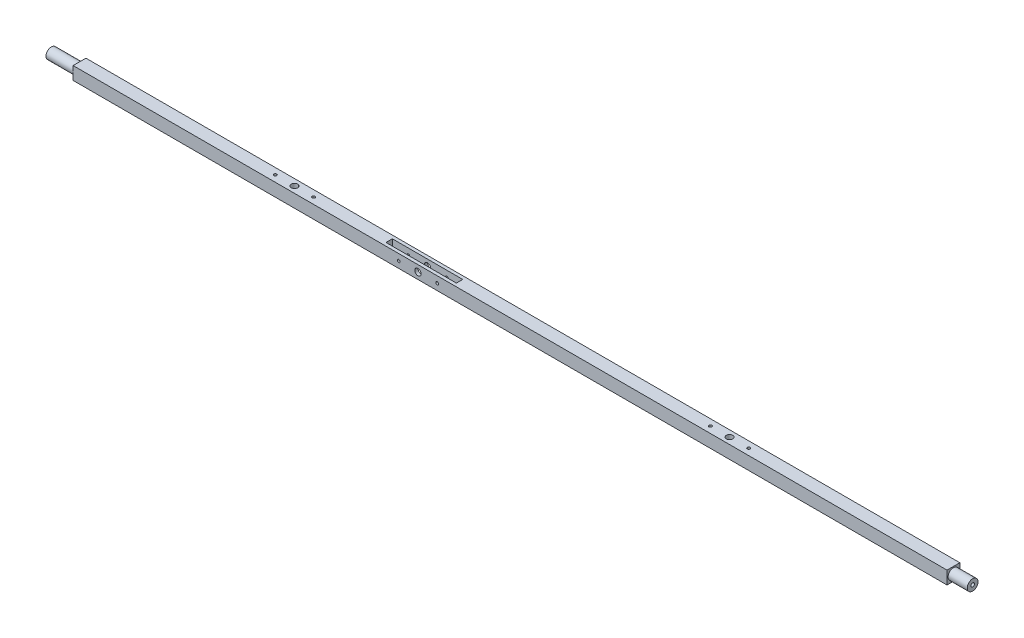
from build123d import *

# Parameters (mm, degrees)
SKETCH1_W                       = 12.7
SKETCH1_H                       = 12.82133758
LENGTH_DEPTH                    = 457.2
SKETCH2_W                       = 12.7
SKETCH2_H                       = 12.82133758
SKETCH2_R                       = 5.334
ROUND_CUT_1_DEPTH               = 19.05
SKETCH3_W                       = 12.7
SKETCH3_H                       = 12.82133758
SKETCH3_R                       = 5.334
ROUND_CUT_2_DEPTH               = 27.94
SKETCH14_R                      = 1.7526
CUT_EXTRUDE6_DEPTH              = 12.7
SKETCH15_R                      = 1.7526
CUT_EXTRUDE7_DEPTH              = 19.05
BOTTOM_WASHER_R                 = 1.4224
BOTTOM_WASHER_BOLTS_DEPTH       = 10.922
BOTTOM_WASHER_CENTER_BOLT_REACH = 14.821
SKETCH18_R                      = 3.175
TOP_WASHER_CENTER_BOLT_REACH    = 14.821
SKETCH17_R                      = 3.175
SKETCH16_R                      = 1.4224
TOP_WASHER_DEPTH                = 10.922
SKETCH19_W                      = 69.85
SKETCH19_H                      = 6.35
CUT_EXTRUDE8_DEPTH              = 13.82133758
SKETCH20_R                      = 1.397
SKETCH20_R_2                    = 3.175
CUT_EXTRUDE9_DEPTH              = 13.7


with BuildPart() as part:
    # Sketch1 → Length (new body, symmetric)
    with BuildSketch(Plane(origin=(0, 0, 0), x_dir=(0, 0, -1), z_dir=(1, 0, 0))):
        Rectangle(SKETCH1_W, SKETCH1_H)
    extrude(amount=LENGTH_DEPTH, both=True)

    # Sketch2 → Round Cut 1 (cut)
    with BuildSketch(Plane(origin=(457.2, 0, 0), x_dir=(0, 0, -1), z_dir=(1, 0, 0))):
        Rectangle(SKETCH2_W, SKETCH2_H)
        Circle(SKETCH2_R, mode=Mode.SUBTRACT)
    extrude(amount=-ROUND_CUT_1_DEPTH, mode=Mode.SUBTRACT)

    # Sketch3 → Round Cut 2 (cut)
    with BuildSketch(Plane.ZY.offset(457.2)):
        Rectangle(SKETCH3_W, SKETCH3_H)
        Circle(SKETCH3_R, mode=Mode.SUBTRACT)
    extrude(amount=-ROUND_CUT_2_DEPTH, mode=Mode.SUBTRACT)

    # Sketch14 → Cut-Extrude6 (cut)
    with BuildSketch(Plane(origin=(457.2, 0, 0), x_dir=(0, 0, -1), z_dir=(1, 0, 0))):
        Circle(SKETCH14_R)
    extrude(amount=-CUT_EXTRUDE6_DEPTH, mode=Mode.SUBTRACT)

    # Sketch15 → Cut-Extrude7 (cut)
    with BuildSketch(Plane.ZY.offset(457.2)):
        Circle(SKETCH15_R)
    extrude(amount=-CUT_EXTRUDE7_DEPTH, mode=Mode.SUBTRACT)

    # Bottom Washer → Bottom washer bolts (cut)
    with BuildSketch(Plane(origin=(0, 6.41066879, 0), x_dir=(1, 0, 0), z_dir=(0, 1, 0))):
        with Locations((-196.85, 0)):
            Circle(BOTTOM_WASHER_R)
        with Locations((-234.95, 0)):
            Circle(BOTTOM_WASHER_R)
    extrude(amount=-BOTTOM_WASHER_BOLTS_DEPTH, mode=Mode.SUBTRACT)

    # Sketch18 → Bottom Washer Center Bolt (cut, up to next)
    with BuildSketch(Plane(origin=(0, 6.41066879, 0), x_dir=(1, 0, 0), z_dir=(0, 1, 0)), mode=Mode.PRIVATE) as bottom_washer_center_bolt_sk1:
        with Locations((-215.9, 0)):
            Circle(SKETCH18_R)
    bottom_washer_center_bolt_tool1 = extrude(bottom_washer_center_bolt_sk1.sketch, amount=-BOTTOM_WASHER_CENTER_BOLT_REACH, mode=Mode.PRIVATE) & part.part
    add(bottom_washer_center_bolt_tool1.solids().sort_by_distance((-215.9, 6.410669, 0))[0], mode=Mode.SUBTRACT)

    # Sketch17 → Top Washer Center Bolt (cut, up to next)
    with BuildSketch(Plane(origin=(0, 6.41066879, 0), x_dir=(1, 0, 0), z_dir=(0, 1, 0)), mode=Mode.PRIVATE) as top_washer_center_bolt_sk1:
        with Locations((215.9, 0)):
            Circle(SKETCH17_R)
    top_washer_center_bolt_tool1 = extrude(top_washer_center_bolt_sk1.sketch, amount=-TOP_WASHER_CENTER_BOLT_REACH, mode=Mode.PRIVATE) & part.part
    add(top_washer_center_bolt_tool1.solids().sort_by_distance((215.9, 6.410669, 0))[0], mode=Mode.SUBTRACT)

    # Sketch16 → Top Washer (cut)
    with BuildSketch(Plane(origin=(0, 6.41066879, 0), x_dir=(1, 0, 0), z_dir=(0, 1, 0))):
        with Locations((234.95, 0)):
            Circle(SKETCH16_R)
        with Locations((196.85, 0)):
            Circle(SKETCH16_R)
    extrude(amount=-TOP_WASHER_DEPTH, mode=Mode.SUBTRACT)

    # Sketch19 → Cut-Extrude8 (cut, through all)
    with BuildSketch(Plane(origin=(0, -6.41066879, 0), x_dir=(-1, 0, 0), z_dir=(0, -1, 0))):
        with Locations((86.985602, 0)):
            Rectangle(SKETCH19_W, SKETCH19_H)
    extrude(amount=-CUT_EXTRUDE8_DEPTH, mode=Mode.SUBTRACT)

    # Sketch20 → Cut-Extrude9 (cut, through all)
    with BuildSketch(Plane.XY.offset(6.35)):
        with Locations((-106.035602, 0)):
            Circle(SKETCH20_R)
        with Locations((-86.985602, 0)):
            Circle(SKETCH20_R_2)
        with Locations((-67.935602, 0)):
            Circle(SKETCH20_R)
    extrude(amount=-CUT_EXTRUDE9_DEPTH, mode=Mode.SUBTRACT)


solid = part.part
